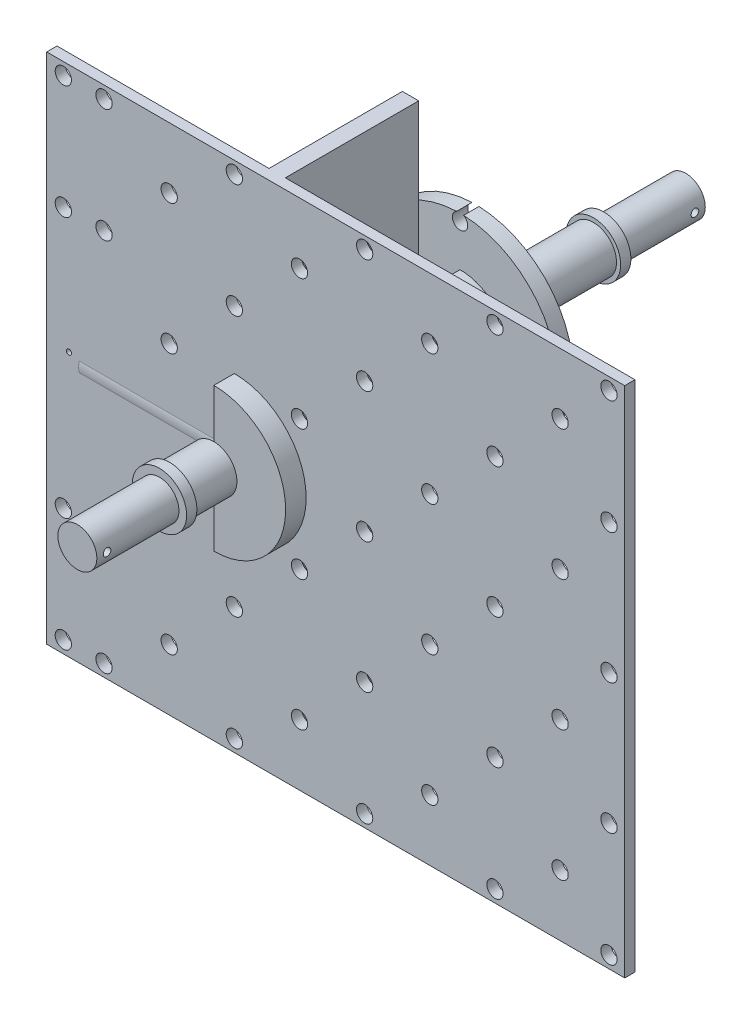
from build123d import *

# Parameters (mm, degrees)
SKETCH1_R            = 3.8
EXTRUDE1_DEPTH       = 16
SKETCH2_R            = 4.5
EXTRUDE2_DEPTH       = 21
SKETCH3_R            = 11.1
EXTRUDE3_DEPTH       = 4
SKETCH4_R            = 19.05
SKETCH4_R_2          = 6.35
EXTRUDE4_DEPTH       = 3
SKETCH5_R            = 1.5
EXTRUDE5_DEPTH       = 3
EXTRUDE9_DEPTH       = 16
EXTRUDE10_DEPTH      = 26
SKETCH11_R           = 1.5875
SKETCH11_R_2         = 0.5
EXTRUDE11_DEPTH      = 2
EXTRUDE15_DEPTH      = 4
SKETCH17_R           = 4.5
EXTRUDE16_DEPTH      = 10.6
SKETCH18_R           = 3.8
EXTRUDE17_DEPTH      = 16
SKETCH19_R           = 5.3
EXTRUDE19_DEPTH      = 2
SKETCH20_R           = 5.3
EXTRUDE20_DEPTH      = 2
SKETCH21_R           = 4.3125
SKETCH21_R_2         = 2.2
EXTRUDE21_DEPTH      = 35
SKETCH22_R           = 1.5
EXTRUDE22_DEPTH      = 25
SKETCH23_R           = 0.75
EXTRUDE23_DEPTH      = 77.101424229
EXTRUDE23_DEPTH_BACK = 37.571496576


with BuildPart() as part:
    # Sketch1 → Extrude1 (new body)
    with BuildSketch(Plane.XY):
        Circle(SKETCH1_R)
    extrude(amount=EXTRUDE1_DEPTH)

    # Sketch2 → Extrude2 (add)
    with BuildSketch(Plane.XY.offset(16)):
        Circle(SKETCH2_R)
    extrude(amount=EXTRUDE2_DEPTH)

    # Sketch3 → Extrude3 (add)
    with BuildSketch(Plane.XY.offset(37)):
        Circle(SKETCH3_R)
    extrude(amount=EXTRUDE3_DEPTH)

    # Sketch4 → Extrude4 (add)
    with BuildSketch(Plane.XY.offset(41)):
        Circle(SKETCH4_R)
        Circle(SKETCH4_R_2, mode=Mode.SUBTRACT)
    extrude(amount=EXTRUDE4_DEPTH)

    # Sketch5 → Extrude5 (cut)
    with BuildSketch(Plane.XY.offset(44)):
        with Locations((17.7, 0)):
            Circle(SKETCH5_R)
        with Locations((0, -17.7)):
            Circle(SKETCH5_R)
        with Locations((0, 17.7)):
            Circle(SKETCH5_R)
        with Locations((-17.7, 0)):
            Circle(SKETCH5_R)
    extrude(amount=-EXTRUDE5_DEPTH, mode=Mode.SUBTRACT)

    # Sketch9 → Extrude9 (add)
    with BuildSketch(Plane.XY.offset(44)):
        with BuildLine():
            Line((0, -6.35), (0, -9.525))
            ThreePointArc((0, -9.525), (3.040285092, -9.02675421), (5.7625, -7.584142585))
            Line((5.7625, -7.584142585), (5.7625, -2.667600748))
            ThreePointArc((5.7625, -2.667600748), (3.419300751, -5.350783342), (0, -6.35))
        make_face()
        with BuildLine():
            Line((5.7625, 2.667600748), (5.7625, 7.584142585))
            ThreePointArc((5.7625, 7.584142585), (3.040285092, 9.02675421), (0, 9.525))
            Line((0, 9.525), (0, 6.35))
            ThreePointArc((0, 6.35), (3.419300751, 5.350783342), (5.7625, 2.667600748))
        make_face()
    extrude(amount=EXTRUDE9_DEPTH)

    # Sketch10 → Extrude10 (add)
    with BuildSketch(Plane.XY.offset(60)):
        with BuildLine():
            Line((4.7625, -8.248891971), (4.7625, -50))
            Line((4.7625, -50), (7.942192923, -50))
            Line((7.942192923, -50), (7.9375, 50))
            Line((7.9375, 50), (4.7625, 50))
            Line((4.7625, 50), (4.7625, 8.248891971))
            ThreePointArc((4.7625, 8.248891971), (2.465251405, 9.200443495), (0, 9.525))
            Line((0, 9.525), (0, 6.35))
            ThreePointArc((0, 6.35), (2.612630206, 5.787630206), (4.7625, 4.200130206))
            Line((4.7625, 4.200130206), (4.7625, -4.200130206))
            ThreePointArc((4.7625, -4.200130206), (2.612630206, -5.787630206), (0, -6.35))
            Line((0, -6.35), (0, -9.525))
            ThreePointArc((0, -9.525), (2.465251405, -9.200443495), (4.7625, -8.248891971))
        make_face()
    extrude(amount=EXTRUDE10_DEPTH)

    # Sketch11 → Extrude11 (add)
    with BuildSketch(Plane.XY.offset(86)):
        Polygon((4.7625, -50), (7.942192923, -50), (76.101424229, -50), (76.101424229, 50), (7.9375, 50), (4.7625, 50), (-36.571496576, 50), (-36.571496576, -50), align=None)
        with Locations((50.8, 25.4)):
            Circle(SKETCH11_R, mode=Mode.SUBTRACT)
        with Locations((25.4, 25.4)):
            Circle(SKETCH11_R, mode=Mode.SUBTRACT)
        with Locations((0, 25.4)):
            Circle(SKETCH11_R, mode=Mode.SUBTRACT)
        with Locations((-25.4, 25.4)):
            Circle(SKETCH11_R, mode=Mode.SUBTRACT)
        with Locations((-32.2375, 1.5)):
            Circle(SKETCH11_R_2, mode=Mode.SUBTRACT)
        Circle(SKETCH11_R, mode=Mode.SUBTRACT)
        with Locations((25.4, 0)):
            Circle(SKETCH11_R, mode=Mode.SUBTRACT)
        with Locations((50.8, 0)):
            Circle(SKETCH11_R, mode=Mode.SUBTRACT)
        with Locations((50.8, -25.4)):
            Circle(SKETCH11_R, mode=Mode.SUBTRACT)
        with Locations((25.4, -25.4)):
            Circle(SKETCH11_R, mode=Mode.SUBTRACT)
        with Locations((0, -25.4)):
            Circle(SKETCH11_R, mode=Mode.SUBTRACT)
        with Locations((-25.4, -25.4)):
            Circle(SKETCH11_R, mode=Mode.SUBTRACT)
        with Locations((63.5, -38.1)):
            Circle(SKETCH11_R, mode=Mode.SUBTRACT)
        with Locations((38.1, -38.1)):
            Circle(SKETCH11_R, mode=Mode.SUBTRACT)
        with Locations((73.025, -47.625)):
            Circle(SKETCH11_R, mode=Mode.SUBTRACT)
        with Locations((-12.7, -38.1)):
            Circle(SKETCH11_R, mode=Mode.SUBTRACT)
        with Locations((12.7, -38.1)):
            Circle(SKETCH11_R, mode=Mode.SUBTRACT)
        with Locations((-33.3375, -47.625)):
            Circle(SKETCH11_R, mode=Mode.SUBTRACT)
        with Locations((63.5, -12.7)):
            Circle(SKETCH11_R, mode=Mode.SUBTRACT)
        with Locations((38.1, -12.7)):
            Circle(SKETCH11_R, mode=Mode.SUBTRACT)
        with Locations((12.7, -12.7)):
            Circle(SKETCH11_R, mode=Mode.SUBTRACT)
        with Locations((63.5, 12.7)):
            Circle(SKETCH11_R, mode=Mode.SUBTRACT)
        with Locations((38.1, 12.7)):
            Circle(SKETCH11_R, mode=Mode.SUBTRACT)
        with Locations((63.5, 38.1)):
            Circle(SKETCH11_R, mode=Mode.SUBTRACT)
        with Locations((38.1, 38.1)):
            Circle(SKETCH11_R, mode=Mode.SUBTRACT)
        with Locations((12.7, 38.1)):
            Circle(SKETCH11_R, mode=Mode.SUBTRACT)
        with Locations((-12.7, 38.1)):
            Circle(SKETCH11_R, mode=Mode.SUBTRACT)
        with Locations((-12.7, 12.7)):
            Circle(SKETCH11_R, mode=Mode.SUBTRACT)
        with Locations((73.025, 47.625)):
            Circle(SKETCH11_R, mode=Mode.SUBTRACT)
        with Locations((50.8, -47.625)):
            Circle(SKETCH11_R, mode=Mode.SUBTRACT)
        with Locations((25.4, -47.625)):
            Circle(SKETCH11_R, mode=Mode.SUBTRACT)
        with Locations((0, -47.625)):
            Circle(SKETCH11_R, mode=Mode.SUBTRACT)
        with Locations((-25.4, -47.625)):
            Circle(SKETCH11_R, mode=Mode.SUBTRACT)
        with Locations((50.8, 47.625)):
            Circle(SKETCH11_R, mode=Mode.SUBTRACT)
        with Locations((25.4, 47.625)):
            Circle(SKETCH11_R, mode=Mode.SUBTRACT)
        with Locations((0, 47.625)):
            Circle(SKETCH11_R, mode=Mode.SUBTRACT)
        with Locations((-25.4, 47.625)):
            Circle(SKETCH11_R, mode=Mode.SUBTRACT)
        with Locations((-33.3375, 47.625)):
            Circle(SKETCH11_R, mode=Mode.SUBTRACT)
        with Locations((73.025, 0)):
            Circle(SKETCH11_R, mode=Mode.SUBTRACT)
        with Locations((73.025, -25.4)):
            Circle(SKETCH11_R, mode=Mode.SUBTRACT)
        with Locations((73.025, 25.4)):
            Circle(SKETCH11_R, mode=Mode.SUBTRACT)
        with Locations((-33.3375, 25.4)):
            Circle(SKETCH11_R, mode=Mode.SUBTRACT)
        with Locations((-33.3375, -25.4)):
            Circle(SKETCH11_R, mode=Mode.SUBTRACT)
        with Locations((-12.7, -12.7)):
            Circle(SKETCH11_R, mode=Mode.SUBTRACT)
        with Locations((12.7, 12.7)):
            Circle(SKETCH11_R, mode=Mode.SUBTRACT)
    extrude(amount=EXTRUDE11_DEPTH)

    # Sketch21 → Extrude21 (add)
    with BuildSketch(Plane.ZY.offset(-4.7625)):
        with Locations((83.8, 0)):
            Circle(SKETCH21_R)
        with Locations((83.8, 0)):
            Circle(SKETCH21_R_2, mode=Mode.SUBTRACT)
    extrude(amount=EXTRUDE21_DEPTH)

    # Sketch22 → Extrude22 (cut)
    with BuildSketch(Plane.ZY.offset(-4.7625)):
        with Locations((83.8, 0)):
            Circle(SKETCH22_R)
    extrude(amount=-EXTRUDE22_DEPTH, mode=Mode.SUBTRACT)


with BuildPart() as body_2:
    # Sketch16 → Extrude15 (new body)
    with BuildSketch(Plane.XY.offset(88)):
        with BuildLine():
            Line((0, -14), (0, 14))
            ThreePointArc((0, 14), (14, 0), (0, -14))
        make_face()
    extrude(amount=EXTRUDE15_DEPTH)

    # Sketch17 → Extrude16 (add)
    with BuildSketch(Plane.XY.offset(92)):
        Circle(SKETCH17_R)
    extrude(amount=EXTRUDE16_DEPTH)

    # Sketch18 → Extrude17 (add)
    with BuildSketch(Plane.XY.offset(102.6)):
        Circle(SKETCH18_R)
    extrude(amount=EXTRUDE17_DEPTH)

    # Sketch20 → Extrude20 (add)
    with BuildSketch(Plane.XY.offset(102.6)):
        Circle(SKETCH20_R)
    extrude(amount=-EXTRUDE20_DEPTH)


with BuildPart() as body_3:
    # Sketch19 → Extrude19 (new body)
    with BuildSketch(Plane(origin=(0, 0, 16), x_dir=(-1, 0, 0), z_dir=(0, 0, -1))):
        Circle(SKETCH19_R)
    extrude(amount=-EXTRUDE19_DEPTH)


with BuildPart() as extrude23_tool:
    # Sketch23 → Extrude23 (new body, two sides)
    with BuildSketch(Plane(origin=(0, 0, 0), x_dir=(0, 0, -1), z_dir=(1, 0, 0))) as extrude23_sk:
        with Locations((-116.6, 0)):
            Circle(SKETCH23_R)
        with Locations((-2, 0)):
            Circle(SKETCH23_R)
    extrude(amount=EXTRUDE23_DEPTH)
    extrude(extrude23_sk.sketch, amount=-EXTRUDE23_DEPTH_BACK)


with BuildPart() as part_1:
    add(part.part)

    # Extrude23: cut by extrude23_tool
    add(extrude23_tool.part, mode=Mode.SUBTRACT)


with BuildPart() as body_2_1:
    add(body_2.part)

    # Extrude23: cut by extrude23_tool
    add(extrude23_tool.part, mode=Mode.SUBTRACT)


solid = Compound([body_3.part, part_1.part, body_2_1.part])
